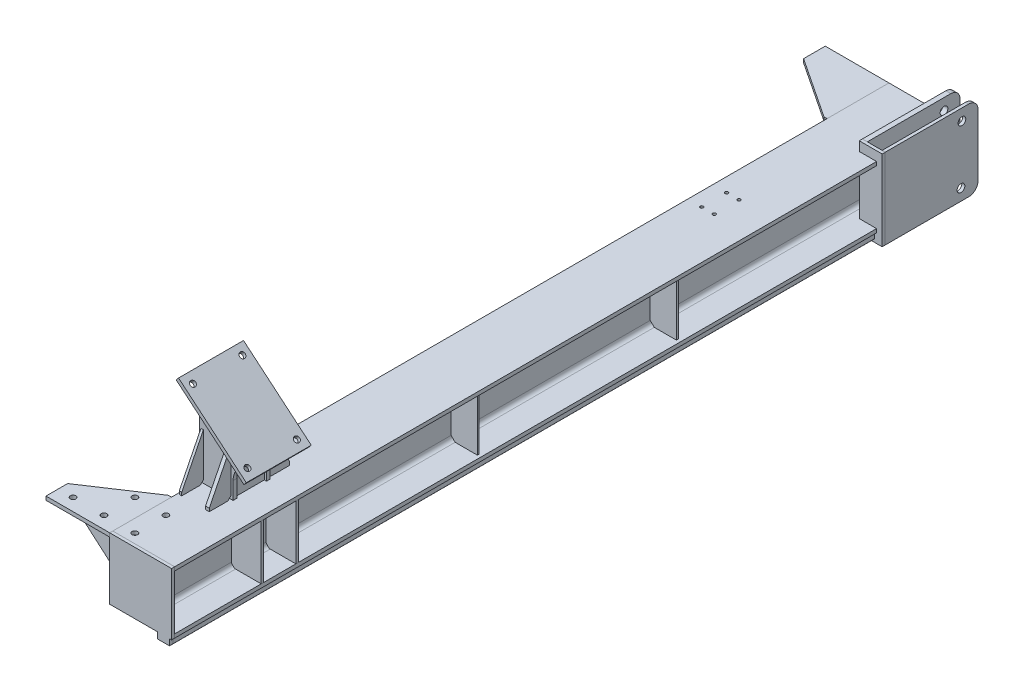
from build123d import *

# Parameters (mm, degrees)
H_HW200A_1_DEPTH     = 2410
MEMBER_1589_DEPTH    = 2410
EXTRUDE_1_DEPTH      = 10
CUT_EXTRUDE_START    = -260
SKETCH_17_W          = 56
SKETCH_17_H          = 140
CUT_EXTRUDE_1_DEPTH  = 260
SKETCH_18_W          = 16
SKETCH_18_H          = 300
EXTRUDE_2_DEPTH      = 260
SKETCH_18_W_2        = 10
EXTRUDE_2_2_DEPTH    = 260
FILLET_1_R           = 30
FILLET_2_R           = 30
SKETCH_19_W          = 74
SKETCH_19_H          = 10
EXTRUDE_3_DEPTH      = 260
CUT_EXTRUDE_START_2  = -74
SKETCH_20_R          = 12.5
CUT_EXTRUDE_2_DEPTH  = 74
SKETCH_21_W          = 48
SKETCH_21_H          = 110
EXTRUDE_5_DEPTH      = 8
EXTRUDE_6_DEPTH      = 105
SKETCH_25_R          = 9
CUT_EXTRUDE_4_DEPTH  = 12
EXTRUDE_7_DEPTH      = 48
EXTRUDE_8_DEPTH      = 12
EXTRUDE_8_2_DEPTH    = 12
EXTRUDE_11_DEPTH     = 12
EXTRUDE_11_2_DEPTH   = 12
SKETCH_32_W          = 40
SKETCH_32_H          = 30
CUT_EXTRUDE_9_DEPTH  = 2280
EXTRUDE_12_DEPTH     = 100
EXTRUDE_13_DEPTH     = 12
EXTRUDE_14_DEPTH     = 12
EXTRUDE_15_DEPTH     = 10
EXTRUDE_16_DEPTH     = 10
SKETCH_38_R          = 9
CUT_EXTRUDE_10_DEPTH = 10
SKETCH_39_R          = 9
CUT_EXTRUDE_11_DEPTH = 12
EXTRUDE_18_DEPTH     = 6
EXTRUDE_19_DEPTH     = 6
SKETCH_43_R          = 5
CUT_EXTRUDE_12_DEPTH = 12
SKETCH_112_W         = 74
SKETCH_112_H         = 2270
CUT_EXTRUDE_13_DEPTH = 30
EXTRUDE_20_DEPTH     = 2270
CUT_EXTRUDE_14_DEPTH = 10
SKETCH_115_W         = 96
SKETCH_115_H         = 176
EXTRUDE_21_DEPTH     = 8
SKETCH_115_W_2       = 280
EXTRUDE_21_2_DEPTH   = 8
SKETCH_115_W_3       = 200
EXTRUDE_21_3_DEPTH   = 8
SKETCH_116_W         = 96
SKETCH_116_H         = 261.438979591
EXTRUDE_22_DEPTH     = 8
EXTRUDE_23_DEPTH     = 8
EXTRUDE_24_DEPTH     = 8
EXTRUDE_25_DEPTH     = 12
EXTRUDE_25_2_DEPTH   = 12
EXTRUDE_26_DEPTH     = 8
EXTRUDE_26_2_DEPTH   = 8
SKETCH_123_W         = 200
SKETCH_123_H         = 176
EXTRUDE_27_DEPTH     = 8
SKETCH_123_W_2       = 300
EXTRUDE_27_2_DEPTH   = 8


with BuildPart() as part:
    # 草图14 → H型钢 HW200A(1) (new body)
    with BuildSketch(Plane(origin=(0, 0, 0), x_dir=(1, 0, 0), z_dir=(0, 0, -1))):
        with BuildLine():
            Line((-100, -100), (100, -100))
            Line((100, -100), (100, -88))
            Line((100, -88), (17, -88))
            ThreePointArc((17, -88), (7.807611845, -84.192388155), (4, -75))
            Line((4, -75), (4, 75))
            ThreePointArc((4, 75), (7.807611845, 84.192388155), (17, 88))
            Line((17, 88), (100, 88))
            Line((100, 88), (100, 100))
            Line((100, 100), (-100, 100))
            Line((-100, 100), (-100, 88))
            Line((-100, 88), (-17, 88))
            ThreePointArc((-17, 88), (-7.807611845, 84.192388155), (-4, 75))
            Line((-4, 75), (-4, -75))
            ThreePointArc((-4, -75), (-7.807611845, -84.192388155), (-17, -88))
            Line((-17, -88), (-100, -88))
            Line((-100, -88), (-100, -100))
        make_face()
    extrude(amount=H_HW200A_1_DEPTH)


with BuildPart() as body_2:
    # 草图13 → Member 1589 (new body)
    with BuildSketch(Plane(origin=(94, 130, -2410), x_dir=(1, 0, 0), z_dir=(0, 0, 1))):
        with BuildLine():
            Line((-38, 0), (-2, 0))
            ThreePointArc((-2, 0), (-0.585786438, -0.585786438), (0, -2))
            Line((0, -2), (0, -30))
            Line((0, -30), (-40, -30))
            Line((-40, -30), (-40, -2))
            ThreePointArc((-40, -2), (-39.414213562, -0.585786438), (-38, 0))
        make_face()
    extrude(amount=MEMBER_1589_DEPTH)


with BuildPart() as body_3:
    # 镜向1: mirrored copy
    add(body_2.part.mirror(Plane.ZX))


with BuildPart() as body_4:
    # 草图16 → 凸台-拉伸1 (new body)
    with BuildSketch(Plane.XY):
        with BuildLine():
            Line((94, -100), (100, -100))
            Line((100, -100), (100, 100))
            Line((100, 100), (94, 100))
            Line((94, 100), (94, 128))
            ThreePointArc((94, 128), (93.414213562, 129.414213562), (92, 130))
            Line((92, 130), (56, 130))
            ThreePointArc((56, 130), (54.585786438, 129.414213562), (54, 128))
            Line((54, 128), (54, 100))
            Line((54, 100), (-100, 100))
            Line((-100, 100), (-100, -100))
            Line((-100, -100), (54, -100))
            Line((54, -100), (54, -128))
            ThreePointArc((54, -128), (54.585786438, -129.414213562), (56, -130))
            Line((56, -130), (92, -130))
            ThreePointArc((92, -130), (93.414213562, -129.414213562), (94, -128))
            Line((94, -128), (94, -100))
        make_face()
    extrude(amount=EXTRUDE_1_DEPTH)


with BuildPart() as cut_extrude_1_tool:
    # 草图17 → 切除-拉伸1 (new body)
    with BuildSketch(Plane(origin=(0, 130, 0), x_dir=(1, 0, 0), z_dir=(0, 1, 0)).offset(CUT_EXTRUDE_START)):
        with Locations((72, 2340)):
            Rectangle(SKETCH_17_W, SKETCH_17_H)
    extrude(amount=CUT_EXTRUDE_1_DEPTH)


with BuildPart() as part_1:
    add(part.part)

    # 切除-拉伸1: cut by cut_extrude_1_tool
    add(cut_extrude_1_tool.part, mode=Mode.SUBTRACT)

    # 草图33 → 凸台-拉伸12 (add)
    with BuildSketch(Plane(origin=(0, 0, -2410), x_dir=(-1, 0, 0), z_dir=(0, 0, -1))):
        with BuildLine():
            Line((-44, 100), (-44, 88))
            Line((-44, 88), (-17, 88))
            ThreePointArc((-17, 88), (-7.807611845, 84.192388155), (-4, 75))
            Line((-4, 75), (-4, -75))
            ThreePointArc((-4, -75), (-7.807611845, -84.192388155), (-17, -88))
            Line((-17, -88), (-44, -88))
            Line((-44, -88), (-44, -100))
            Line((-44, -100), (100, -100))
            Line((100, -100), (100, -88))
            Line((100, -88), (17, -88))
            ThreePointArc((17, -88), (7.807611845, -84.192388155), (4, -75))
            Line((4, -75), (4, 75))
            ThreePointArc((4, 75), (7.807611845, 84.192388155), (17, 88))
            Line((17, 88), (100, 88))
            Line((100, 88), (100, 100))
            Line((100, 100), (-44, 100))
        make_face()
    extrude(amount=EXTRUDE_12_DEPTH)


with BuildPart() as body_2_1:
    add(body_2.part)

    # 切除-拉伸1: cut by cut_extrude_1_tool
    add(cut_extrude_1_tool.part, mode=Mode.SUBTRACT)


with BuildPart() as body_3_1:
    add(body_3.part)

    # 切除-拉伸1: cut by cut_extrude_1_tool
    add(cut_extrude_1_tool.part, mode=Mode.SUBTRACT)

    # 草图112 → 切除-拉伸13 (cut)
    with BuildSketch(Plane.XZ.offset(130)):
        with Locations((81, -1135)):
            Rectangle(SKETCH_112_W, SKETCH_112_H)
    extrude(amount=-CUT_EXTRUDE_13_DEPTH, mode=Mode.SUBTRACT)


with BuildPart() as body_5:
    # 草图18 → 凸台-拉伸2 (new body)
    with BuildSketch(Plane(origin=(0, 130, 0), x_dir=(1, 0, 0), z_dir=(0, 1, 0))):
        with Locations((52, 2430)):
            Rectangle(SKETCH_18_W, SKETCH_18_H)
    extrude(amount=-EXTRUDE_2_DEPTH)

    # 圆角2
    fillet_2_edges = [body_5.edges().sort_by_distance(p)[0] for p in [
        (52, -130, -2580),
        (52, 130, -2580),
    ]]
    fillet(fillet_2_edges, radius=FILLET_2_R)


with BuildPart() as body_6:
    # 草图18 → Extrude 2 2 (new body)
    with BuildSketch(Plane(origin=(0, 130, 0), x_dir=(1, 0, 0), z_dir=(0, 1, 0))):
        with Locations((113, 2430)):
            Rectangle(SKETCH_18_W_2, SKETCH_18_H)
    extrude(amount=-EXTRUDE_2_2_DEPTH)

    # 圆角1
    fillet_1_edges = [body_6.edges().sort_by_distance(p)[0] for p in [
        (113, -130, -2580),
        (113, 130, -2580),
    ]]
    fillet(fillet_1_edges, radius=FILLET_1_R)


with BuildPart() as body_7:
    # 草图19 → 凸台-拉伸3 (new body)
    with BuildSketch(Plane(origin=(0, 130, 0), x_dir=(1, 0, 0), z_dir=(0, 1, 0))):
        with Locations((81, 2275)):
            Rectangle(SKETCH_19_W, SKETCH_19_H)
    extrude(amount=-EXTRUDE_3_DEPTH)


with BuildPart() as cut_extrude_2_tool:
    # 草图20 → 切除-拉伸2 (new body)
    with BuildSketch(Plane(origin=(118, 0, 0), x_dir=(0, 0, -1), z_dir=(1, 0, 0)).offset(CUT_EXTRUDE_START_2)):
        with Locations((2528, 93)):
            Circle(SKETCH_20_R)
        with Locations((2525, -93)):
            Circle(SKETCH_20_R)
    extrude(amount=CUT_EXTRUDE_2_DEPTH)


with BuildPart() as body_5_1:
    add(body_5.part)

    # 切除-拉伸2: cut by cut_extrude_2_tool
    add(cut_extrude_2_tool.part, mode=Mode.SUBTRACT)


with BuildPart() as body_6_1:
    add(body_6.part)

    # 切除-拉伸2: cut by cut_extrude_2_tool
    add(cut_extrude_2_tool.part, mode=Mode.SUBTRACT)


with BuildPart() as body_8:
    # 草图21 → 凸台-拉伸5 (new body)
    with BuildSketch(Plane(origin=(0, 0, -2480), x_dir=(-1, 0, 0), z_dir=(0, 0, -1))):
        with Locations((-84, 0)):
            Rectangle(SKETCH_21_W, SKETCH_21_H)
    extrude(amount=-EXTRUDE_5_DEPTH)


with BuildPart() as body_9:
    # 草图23 → 凸台-拉伸6 (new, symmetric)
    with BuildSketch(Plane.XY.offset(-340)):
        Polygon((89.088710732, 206.970210312), (-130, 390.807466683), (-122.286548684, 400), (96.802162048, 216.16274363), align=None)
    extrude(amount=EXTRUDE_6_DEPTH, both=True)

    # 草图25 → 切除-拉伸4 (cut)
    with BuildSketch(Plane(origin=(146.435694427, 174.515264917, 0), x_dir=(0.7660444431189815, -0.6427876096865355, 0), z_dir=(0.6427876096865355, 0.7660444431189815, 0))):
        with Locations(Location((-322.791974962, 420, 0), (0, 0, 180))):
            Circle(SKETCH_25_R)
        with Locations(Location((-92.791974962, 420, 0), (0, 0, 180))):
            Circle(SKETCH_25_R)
        with Locations(Location((-92.791974962, 260, 0), (0, 0, 180))):
            Circle(SKETCH_25_R)
        with Locations(Location((-322.791974962, 260, 0), (0, 0, 180))):
            Circle(SKETCH_25_R)
    extrude(amount=-CUT_EXTRUDE_4_DEPTH, mode=Mode.SUBTRACT)


with BuildPart() as body_10:
    # 草图24 → 凸台-拉伸7 (new, symmetric)
    with BuildSketch(Plane.XY.offset(-340)):
        Polygon((2, 100), (-10, 100), (-10, 285.080913154), (-4, 285.080913154), (2, 280.046315367), align=None)
    extrude(amount=EXTRUDE_7_DEPTH, both=True)


with BuildPart() as body_11:
    # 草图26 → 凸台-拉伸8 (new body)
    with BuildSketch(Plane(origin=(0, 0, -388), x_dir=(-1, 0, 0), z_dir=(0, 0, -1))):
        with BuildLine():
            Line((-59.088710732, 232.143199248), (100, 365.634477747))
            Line((100, 365.634477747), (100, 100))
            Line((100, 100), (-9, 100))
            Line((-9, 100), (-9, 155.850518171))
            ThreePointArc((-9, 155.850518171), (-13.339344377, 178.253451364), (-25.729713855, 197.415916484))
            Line((-25.729713855, 197.415916484), (-59.088710732, 232.143199248))
        make_face()
    extrude(amount=EXTRUDE_8_DEPTH)


with BuildPart() as body_12:
    # 草图26 → Extrude 8 2 (new body)
    with BuildSketch(Plane(origin=(0, 0, -388), x_dir=(-1, 0, 0), z_dir=(0, 0, -1))):
        Polygon((100, 88), (17, 88), (4, 75), (4, -75), (17, -88), (100, -88), align=None)
    extrude(amount=EXTRUDE_8_2_DEPTH)


with BuildPart() as body_13:
    # 草图27 → 凸台-拉伸11 (new body)
    with BuildSketch(Plane.XY.offset(-292)):
        Polygon((-100, 88), (-100, -88), (-17, -88), (-4, -75), (-4, 75), (-17, 88), align=None)
    extrude(amount=EXTRUDE_11_DEPTH)


with BuildPart() as body_14:
    # 草图27 → Extrude 11 2 (new body)
    with BuildSketch(Plane.XY.offset(-292)):
        with BuildLine():
            Line((59.088710732, 232.143199248), (-100, 365.634477747))
            Line((-100, 365.634477747), (-100, 100))
            Line((-100, 100), (9, 100))
            Line((9, 100), (9, 155.850518171))
            ThreePointArc((9, 155.850518171), (13.339344377, 178.253451364), (25.729713855, 197.415916484))
            Line((25.729713855, 197.415916484), (59.088710732, 232.143199248))
        make_face()
    extrude(amount=EXTRUDE_11_2_DEPTH)


with BuildPart() as cut_extrude_9_tool:
    # 草图32 → 切除-拉伸9 (new body)
    with BuildSketch(Plane.XY.offset(10)):
        with Locations((74, 115)):
            Rectangle(SKETCH_32_W, SKETCH_32_H)
    extrude(amount=-CUT_EXTRUDE_9_DEPTH)


with BuildPart() as body_2_2:
    add(body_2_1.part)

    # 切除-拉伸9: cut by cut_extrude_9_tool
    add(cut_extrude_9_tool.part, mode=Mode.SUBTRACT)


with BuildPart() as body_4_1:
    add(body_4.part)

    # 切除-拉伸9: cut by cut_extrude_9_tool
    add(cut_extrude_9_tool.part, mode=Mode.SUBTRACT)

    # 草图114 → 切除-拉伸14 (cut)
    with BuildSketch(Plane(origin=(0, 0, 0), x_dir=(-1, 0, 0), z_dir=(0, 0, -1))):
        with BuildLine():
            Line((-92, -130), (-56, -130))
            ThreePointArc((-56, -130), (-54.585786438, -129.414213562), (-54, -128))
            Line((-54, -128), (-54, -119))
            ThreePointArc((-54, -119), (-54.292893219, -119.707106781), (-55, -120))
            Line((-55, -120), (-93, -120))
            ThreePointArc((-93, -120), (-93.707106781, -119.707106781), (-94, -119))
            Line((-94, -119), (-94, -128))
            ThreePointArc((-94, -128), (-93.414213562, -129.414213562), (-92, -130))
        make_face()
    extrude(amount=-CUT_EXTRUDE_14_DEPTH, mode=Mode.SUBTRACT)


with BuildPart() as body_14_2:
    # 草图34 → 凸台-拉伸13 (new body)
    with BuildSketch(Plane.XZ.offset(-88)):
        Polygon((-306, 10), (-100, 10), (-100, -190), (-110, -190), (-306, -60), align=None)
    extrude(amount=-EXTRUDE_13_DEPTH)


with BuildPart() as body_15:
    # 草图35 → 凸台-拉伸14 (new body)
    with BuildSketch(Plane.XZ.offset(-88)):
        Polygon((-100, -2510), (-306, -2510), (-306, -2440), (-110, -2310), (-100, -2310), align=None)
    extrude(amount=-EXTRUDE_14_DEPTH)


with BuildPart() as body_16:
    # 草图36 → 凸台-拉伸15 (new body)
    with BuildSketch(Plane.XY.offset(-60)):
        Polygon((-95, 88), (-297, 88), (-297, 78), (-105, -88), (-95, -88), align=None)
    extrude(amount=EXTRUDE_15_DEPTH)


with BuildPart() as body_17:
    # 草图37 → 凸台-拉伸16 (new body)
    with BuildSketch(Plane(origin=(0, 0, -2440), x_dir=(-1, 0, 0), z_dir=(0, 0, -1))):
        Polygon((95, 88), (95, -88), (105, -88), (297, 78), (297, 88), align=None)
    extrude(amount=EXTRUDE_16_DEPTH)


with BuildPart() as cut_extrude_10_tool:
    # 草图38 → 切除-拉伸10 (new body)
    with BuildSketch(Plane(origin=(0, 88, 0), x_dir=(-1, 0, 0), z_dir=(0, -1, 0))):
        with Locations(Location((58.5, 2470, 0), (0, 0, 180))):
            Circle(SKETCH_38_R)
        with Locations(Location((158.5, 2470, 0), (0, 0, 180))):
            Circle(SKETCH_38_R)
        with Locations(Location((258.5, 2470, 0), (0, 0, 180))):
            Circle(SKETCH_38_R)
        with Locations(Location((58.5, 2370, 0), (0, 0, 180))):
            Circle(SKETCH_38_R)
        with Locations(Location((158.5, 2370, 0), (0, 0, 180))):
            Circle(SKETCH_38_R)
    extrude(amount=-CUT_EXTRUDE_10_DEPTH)


with BuildPart() as part_2:
    add(part_1.part)

    # 切除-拉伸10: cut by cut_extrude_10_tool
    add(cut_extrude_10_tool.part, mode=Mode.SUBTRACT)


with BuildPart() as body_15_1:
    add(body_15.part)

    # 切除-拉伸10: cut by cut_extrude_10_tool
    add(cut_extrude_10_tool.part, mode=Mode.SUBTRACT)


with BuildPart() as cut_extrude_11_tool:
    # 草图39 → 切除-拉伸11 (new body)
    with BuildSketch(Plane.XZ.offset(-88)):
        with Locations((-258.5, -30)):
            Circle(SKETCH_39_R)
        with Locations((-158.5, -30)):
            Circle(SKETCH_39_R)
        with Locations((-58.5, -30)):
            Circle(SKETCH_39_R)
        with Locations((-58.5, -130)):
            Circle(SKETCH_39_R)
        with Locations((-158.5, -130)):
            Circle(SKETCH_39_R)
    extrude(amount=-CUT_EXTRUDE_11_DEPTH)


with BuildPart() as part_3:
    add(part_2.part)

    # 切除-拉伸11: cut by cut_extrude_11_tool
    add(cut_extrude_11_tool.part, mode=Mode.SUBTRACT)

    # 草图43 → 切除-拉伸12 (cut)
    with BuildSketch(Plane(origin=(0, 100, 0), x_dir=(1, 0, 0), z_dir=(0, 1, 0))):
        with Locations(Location((-15, 1940, 0), (0, 0, 180))):
            Circle(SKETCH_43_R)
        with Locations(Location((-55, 1940, 0), (0, 0, 180))):
            Circle(SKETCH_43_R)
        with Locations(Location((-55, 1860, 0), (0, 0, 180))):
            Circle(SKETCH_43_R)
        with Locations(Location((-15, 1860, 0), (0, 0, 180))):
            Circle(SKETCH_43_R)
    extrude(amount=-CUT_EXTRUDE_12_DEPTH, mode=Mode.SUBTRACT)


with BuildPart() as body_14_2_1:
    add(body_14_2.part)

    # 切除-拉伸11: cut by cut_extrude_11_tool
    add(cut_extrude_11_tool.part, mode=Mode.SUBTRACT)


with BuildPart() as body_18:
    # 草图41 → 凸台-拉伸18 (new body)
    with BuildSketch(Plane.XY.offset(-990)):
        Polygon((17, -88), (89, -88), (89, 88), (17, 88), (4, 75), (4, -75), align=None)
    extrude(amount=-EXTRUDE_18_DEPTH)


with BuildPart() as body_19:
    # 草图42 → 凸台-拉伸19 (new body)
    with BuildSketch(Plane.XY.offset(-1640)):
        Polygon((4, -75), (17, -88), (89, -88), (89, 88), (17, 88), (4, 75), align=None)
    extrude(amount=EXTRUDE_19_DEPTH)


with BuildPart() as body_19_2:
    # 草图113 → 凸台-拉伸20 (new body)
    with BuildSketch(Plane(origin=(0, 0, 0), x_dir=(-1, 0, 0), z_dir=(0, 0, -1))):
        with BuildLine():
            Line((-94, -100), (-54, -100))
            Line((-54, -100), (-54, -119))
            ThreePointArc((-54, -119), (-54.292893219, -119.707106781), (-55, -120))
            Line((-55, -120), (-93, -120))
            ThreePointArc((-93, -120), (-93.707106781, -119.707106781), (-94, -119))
            Line((-94, -119), (-94, -100))
        make_face()
    extrude(amount=EXTRUDE_20_DEPTH)


with BuildPart() as body_20:
    # 草图115 → 凸台-拉伸21 (new body)
    with BuildSketch(Plane.ZY.offset(95)):
        with Locations((-340, 0)):
            Rectangle(SKETCH_115_W, SKETCH_115_H)
    extrude(amount=-EXTRUDE_21_DEPTH)


with BuildPart() as body_21:
    # 草图115 → Extrude 21 2 (new body)
    with BuildSketch(Plane.ZY.offset(95)):
        with Locations((-140, 0)):
            Rectangle(SKETCH_115_W_2, SKETCH_115_H)
    extrude(amount=-EXTRUDE_21_2_DEPTH)


with BuildPart() as body_22:
    # 草图115 → Extrude 21 3 (new body)
    with BuildSketch(Plane.ZY.offset(95)):
        with Locations((-500, 0)):
            Rectangle(SKETCH_115_W_3, SKETCH_115_H)
    extrude(amount=-EXTRUDE_21_3_DEPTH)


with BuildPart() as body_23:
    # 草图116 → 凸台-拉伸22 (new body)
    with BuildSketch(Plane.ZY.offset(95)):
        with Locations((-340, 230.719489796)):
            Rectangle(SKETCH_116_W, SKETCH_116_H)
    extrude(amount=-EXTRUDE_22_DEPTH)


with BuildPart() as body_24:
    # 草图118 → 凸台-拉伸23 (new body)
    with BuildSketch(Plane(origin=(0, 0, -400), x_dir=(-1, 0, 0), z_dir=(0, 0, -1))):
        Polygon((-100, 88), (-14, 88), (-4, 78), (-4, -78), (-14, -88), (-100, -88), align=None)
    extrude(amount=-EXTRUDE_23_DEPTH)


with BuildPart() as body_25:
    # 草图119 → 凸台-拉伸24 (new body)
    with BuildSketch(Plane.XY.offset(-280)):
        Polygon((100, -88), (100, 88), (14, 88), (4, 78), (4, -78), (14, -88), align=None)
    extrude(amount=-EXTRUDE_24_DEPTH)


with BuildPart() as body_26:
    # 草图120 → 凸台-拉伸25 (new body)
    with BuildSketch(Plane(origin=(2, 0, 0), x_dir=(0, 0, -1), z_dir=(1, 0, 0))):
        Polygon((280, 110), (280, 250), (210, 110), (210, 100), (270, 100), align=None)
    extrude(amount=-EXTRUDE_25_DEPTH)


with BuildPart() as body_27:
    # 草图120 → Extrude 25 2 (new body)
    with BuildSketch(Plane(origin=(2, 0, 0), x_dir=(0, 0, -1), z_dir=(1, 0, 0))):
        Polygon((470, 100), (410, 100), (400, 110), (400, 250), (470, 110), align=None)
    extrude(amount=-EXTRUDE_25_2_DEPTH)


with BuildPart() as body_28:
    # 草图122 → 凸台-拉伸26 (new body)
    with BuildSketch(Plane.ZY.offset(95)):
        Polygon((-470, 110), (-470, 100), (-410, 100), (-400, 110), (-400, 250), align=None)
    extrude(amount=-EXTRUDE_26_DEPTH)


with BuildPart() as body_29:
    # 草图122 → Extrude 26 2 (new body)
    with BuildSketch(Plane.ZY.offset(95)):
        Polygon((-210, 110), (-280, 250), (-280, 110), (-270, 100), (-210, 100), align=None)
    extrude(amount=-EXTRUDE_26_2_DEPTH)


with BuildPart() as body_30:
    # 草图123 → 凸台-拉伸27 (new body)
    with BuildSketch(Plane.ZY.offset(95)):
        with Locations((-2410, 0)):
            Rectangle(SKETCH_123_W, SKETCH_123_H)
    extrude(amount=-EXTRUDE_27_DEPTH)


with BuildPart() as body_31:
    # 草图123 → Extrude 27 2 (new body)
    with BuildSketch(Plane.ZY.offset(95)):
        with Locations((-1460, 0)):
            Rectangle(SKETCH_123_W_2, SKETCH_123_H)
    extrude(amount=-EXTRUDE_27_2_DEPTH)


solid = Compound([body_7.part, body_5_1.part, body_6_1.part, body_8.part, body_9.part, body_10.part, body_11.part, body_12.part, body_13.part, body_14.part, body_4_1.part, body_16.part, body_17.part, body_15_1.part, part_3.part, body_14_2_1.part, body_18.part, body_19.part, body_19_2.part, body_20.part, body_21.part, body_22.part, body_23.part, body_24.part, body_25.part, body_26.part, body_27.part, body_28.part, body_29.part, body_30.part, body_31.part])
